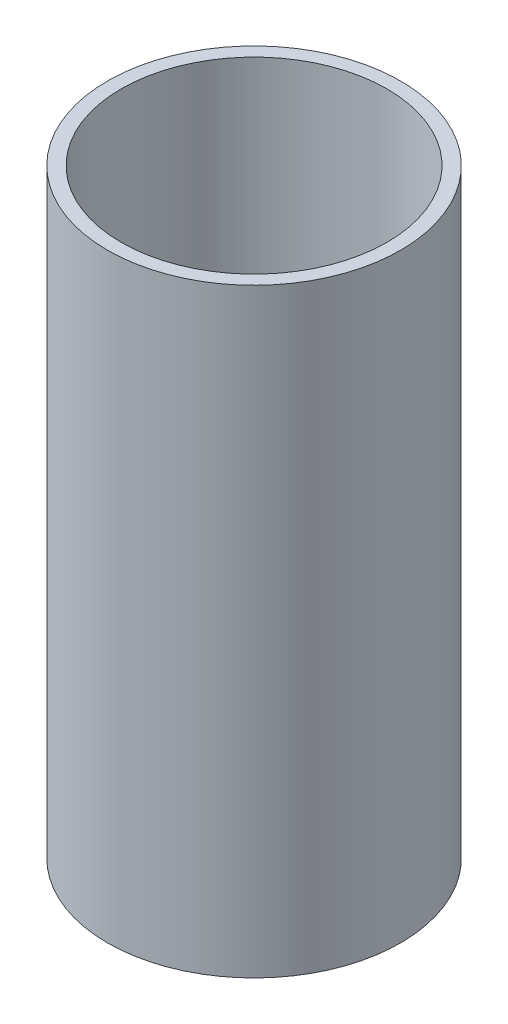
from build123d import *

# Parameters (mm, degrees)
SKETCH1_R           = 10.75
SKETCH1_R_2         = 9.75
BOSS_EXTRUDE1_DEPTH = 44


with BuildPart() as part:
    # Sketch1 → Boss-Extrude1 (new body)
    with BuildSketch(Plane(origin=(0, 0, 0), x_dir=(1, 0, 0), z_dir=(0, 1, 0))):
        Circle(SKETCH1_R)
        Circle(SKETCH1_R_2, mode=Mode.SUBTRACT)
    extrude(amount=BOSS_EXTRUDE1_DEPTH)


solid = part.part
